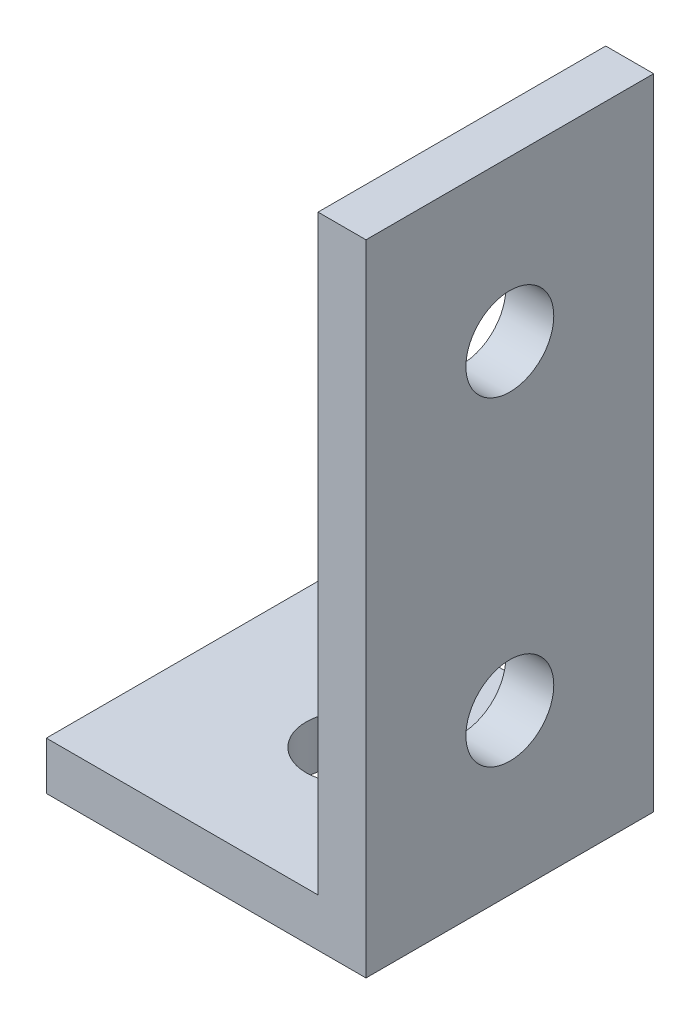
from build123d import *

# Parameters (mm, degrees)
SKETCH_1_W          = 20
SKETCH_1_H          = 18
EXTRUDE_1_DEPTH     = 3
SKETCH_2_W          = 3
SKETCH_2_H          = 18
EXTRUDE_2_DEPTH     = 37
SKETCH_4_R          = 2.75
CUT_EXTRUDE_1_DEPTH = 41
SKETCH_5_R          = 2.75
CUT_EXTRUDE_2_DEPTH = 21


with BuildPart() as part:
    # 草图1 → 凸台-拉伸1 (new body)
    with BuildSketch(Plane(origin=(0, 0, 0), x_dir=(1, 0, 0), z_dir=(0, 1, 0))):
        Rectangle(SKETCH_1_W, SKETCH_1_H)
    extrude(amount=EXTRUDE_1_DEPTH)

    # 草图2 → 凸台-拉伸2 (add)
    with BuildSketch(Plane(origin=(0, 3, 0), x_dir=(1, 0, 0), z_dir=(0, 1, 0))):
        with Locations((8.5, 0)):
            Rectangle(SKETCH_2_W, SKETCH_2_H)
    extrude(amount=EXTRUDE_2_DEPTH)

    # 草图4 → 切除-拉伸1 (cut, through all)
    with BuildSketch(Plane.XZ):
        Circle(SKETCH_4_R)
    extrude(amount=-CUT_EXTRUDE_1_DEPTH, mode=Mode.SUBTRACT)

    # 草图5 → 切除-拉伸2 (cut, through all)
    with BuildSketch(Plane(origin=(10, 0, 0), x_dir=(0, 0, -1), z_dir=(1, 0, 0))):
        with Locations((0, 10)):
            Circle(SKETCH_5_R)
        with Locations((0, 30)):
            Circle(SKETCH_5_R)
    extrude(amount=-CUT_EXTRUDE_2_DEPTH, mode=Mode.SUBTRACT)


solid = part.part
